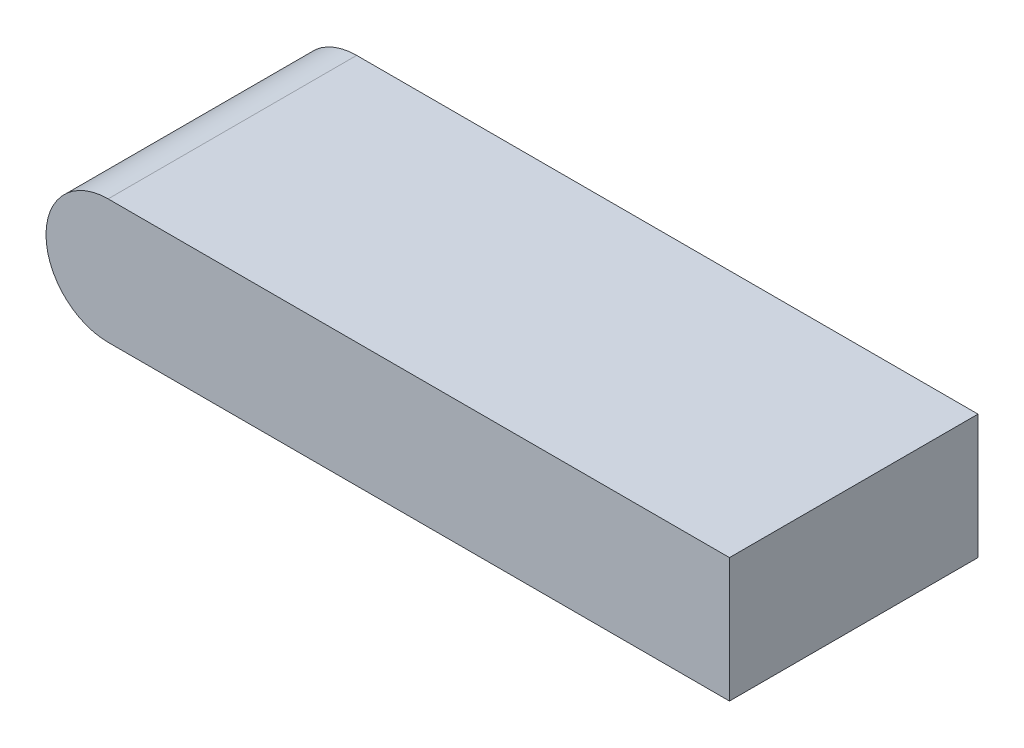
from build123d import *

# Parameters (mm, degrees)
SKETCH_1_W      = 20
SKETCH_1_H      = 8
EXTRUDE_1_DEPTH = 4
SKETCH_2_R      = 2
EXTRUDE_2_DEPTH = 8


with BuildPart() as part:
    # 草图1 → 凸台-拉伸1 (new body)
    with BuildSketch(Plane(origin=(0, 0, 0), x_dir=(1, 0, 0), z_dir=(0, 1, 0))):
        with Locations((-2, 0)):
            Rectangle(SKETCH_1_W, SKETCH_1_H)
    extrude(amount=EXTRUDE_1_DEPTH)

    # 草图2 → 凸台-拉伸2 (add)
    with BuildSketch(Plane.XY.offset(4)):
        with Locations((-12, 2)):
            Circle(SKETCH_2_R)
    extrude(amount=-EXTRUDE_2_DEPTH)


solid = part.part
